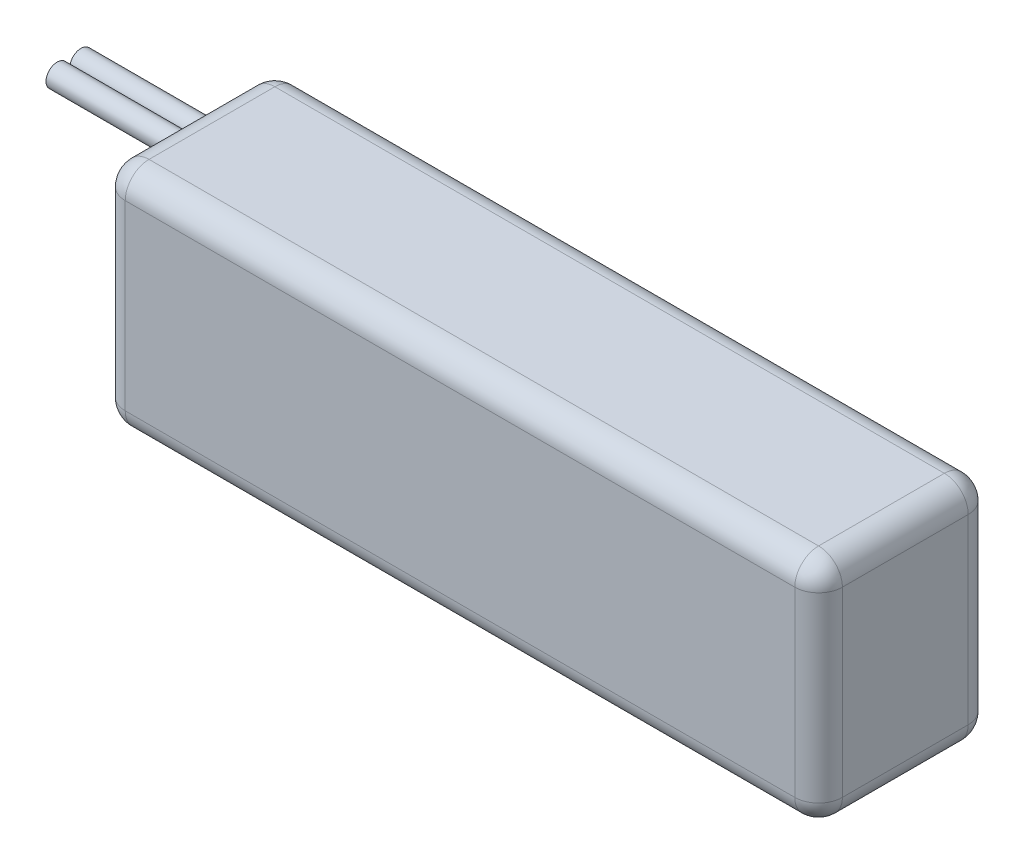
from build123d import *

# Parameters (mm, degrees)
SKETCH1_W                = 153
SKETCH1_H                = 37
BOSS_EXTRUDE1_DEPTH      = 49
FILLET1_R                = 5.08
SKETCH2_R                = 2.38125
BOSS_EXTRUDE2_DEPTH      = 25.4
BOSS_EXTRUDE2_DEPTH_BACK = 25.4


with BuildPart() as part:
    # Sketch1 → Boss-Extrude1 (new body)
    with BuildSketch(Plane(origin=(0, 0, 0), x_dir=(1, 0, 0), z_dir=(0, 1, 0))):
        with Locations((76.5, -18.5)):
            Rectangle(SKETCH1_W, SKETCH1_H)
    extrude(amount=BOSS_EXTRUDE1_DEPTH)

    # Fillet1
    fillet1_edges = [part.edges().sort_by_distance(p)[0] for p in [
        (153, 49, 18.5),
        (76.5, 49, 0),
        (0, 49, 18.5),
        (76.5, 0, 0),
        (153, 0, 18.5),
        (76.5, 0, 37),
        (0, 0, 18.5),
        (76.5, 49, 37),
        (0, 24.5, 0),
        (153, 24.5, 0),
        (153, 24.5, 37),
        (0, 24.5, 37),
    ]]
    fillet(fillet1_edges, radius=FILLET1_R)

    # Sketch2 → Boss-Extrude2 (add, two sides)
    with BuildSketch(Plane.ZY) as boss_extrude2_sk:
        with Locations((15.96, 43.92)):
            Circle(SKETCH2_R)
        with Locations((21.04, 43.92)):
            Circle(SKETCH2_R)
    extrude(amount=BOSS_EXTRUDE2_DEPTH)
    extrude(boss_extrude2_sk.sketch, amount=-BOSS_EXTRUDE2_DEPTH_BACK)


solid = part.part
